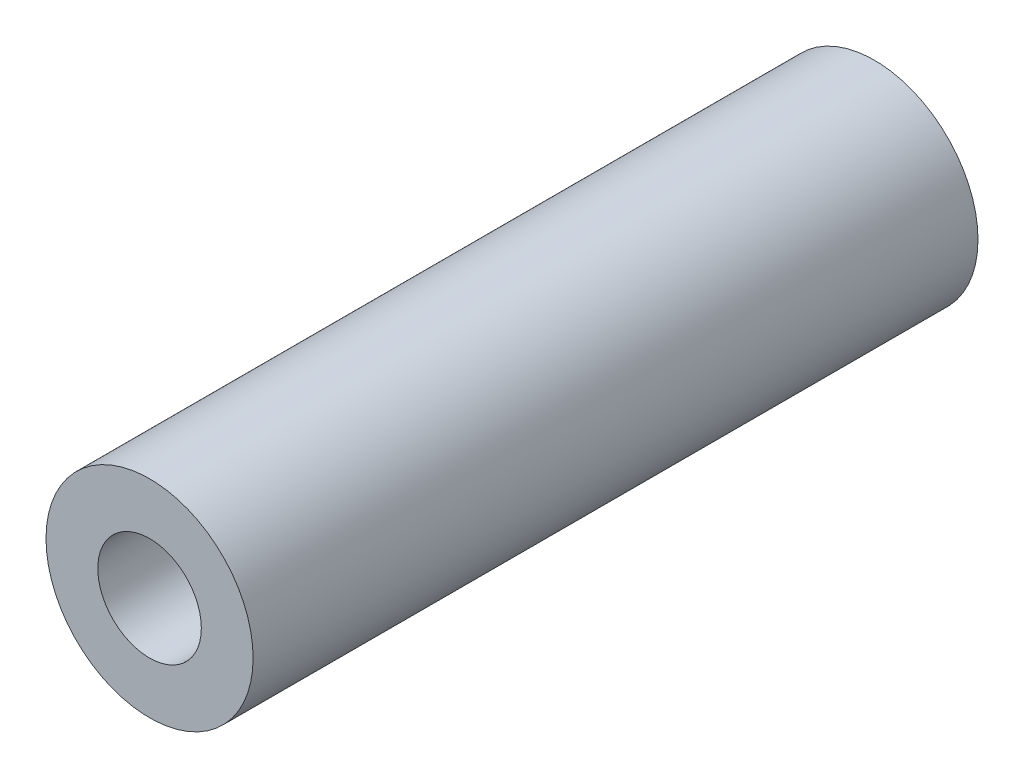
from build123d import *

# Parameters (mm, degrees)
SKETCH1_R           = 11
SKETCH1_R_2         = 5.5
BOSS_EXTRUDE1_DEPTH = 77


with BuildPart() as part:
    # Sketch1 → Boss-Extrude1 (new body)
    with BuildSketch(Plane.XY):
        Circle(SKETCH1_R)
        Circle(SKETCH1_R_2, mode=Mode.SUBTRACT)
    extrude(amount=BOSS_EXTRUDE1_DEPTH)


solid = part.part
